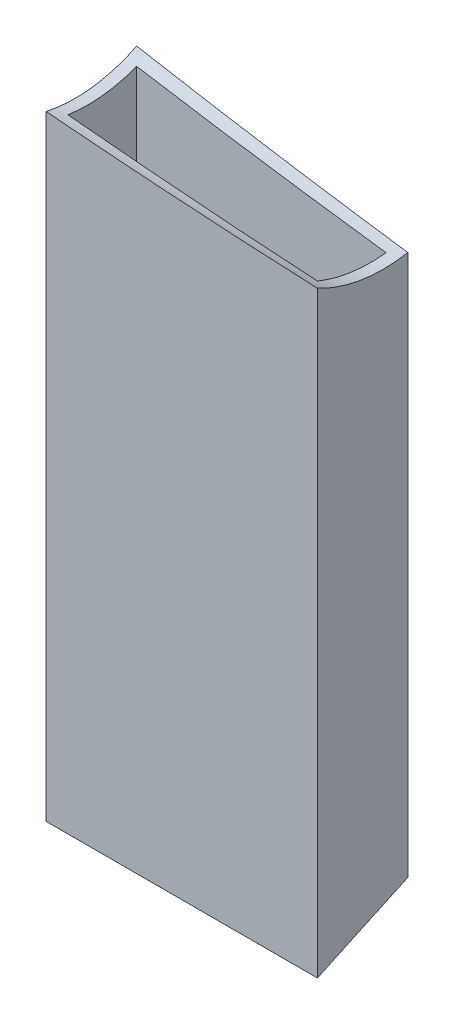
from build123d import *

# Parameters (mm, degrees)
SKETCH1_W           = 76.2
SKETCH1_H           = 25.4
SKETCH1_W_2         = 70.104
SKETCH1_H_2         = 19.304
BOSS_EXTRUDE1_DEPTH = 200
SKETCH3_W           = 76.2
SKETCH3_H           = 25.4
SKETCH3_W_2         = 70.104
SKETCH3_H_2         = 19.304
BOSS_EXTRUDE2_DEPTH = 38.1
CUT_EXTRUDE1_DEPTH  = 77.2
CUT_EXTRUDE5_START  = 13.832764
SKETCH7_R           = 38.1
CUT_EXTRUDE5_DEPTH  = 83.124802


with BuildPart() as part:
    # Sketch1 → Boss-Extrude1 (new body)
    with BuildSketch(Plane(origin=(0, 0, 0), x_dir=(1, 0, 0), z_dir=(0, 1, 0))):
        Rectangle(SKETCH1_W, SKETCH1_H)
        Rectangle(SKETCH1_W_2, SKETCH1_H_2, mode=Mode.SUBTRACT)
    extrude(amount=BOSS_EXTRUDE1_DEPTH)

    # Sketch3 → Boss-Extrude2 (add)
    with BuildSketch(Plane.XZ):
        Rectangle(SKETCH3_W, SKETCH3_H)
        Rectangle(SKETCH3_W_2, SKETCH3_H_2, mode=Mode.SUBTRACT)
    extrude(amount=BOSS_EXTRUDE2_DEPTH)

    # Sketch4 → Cut-Extrude1 (cut, through all)
    with BuildSketch(Plane(origin=(38.1, 0, 0), x_dir=(0, 0, -1), z_dir=(1, 0, 0))):
        Polygon((-18.94463971, -8.788530579), (21.02313948, 9.752758934), (26.07322677, -49.294265894), (-15.918593218, -47.517542491), align=None)
    extrude(amount=-CUT_EXTRUDE1_DEPTH, mode=Mode.SUBTRACT)

    # Sketch7 → Cut-Extrude5 (cut)
    with BuildSketch(Plane(origin=(56.875227758, 193.523427606, -7.656864493), x_dir=(0.131571603, -0.016382038, 0.991171298), z_dir=(-0.984807753, 0.112143352, 0.132580384)).offset(CUT_EXTRUDE5_START)):
        Circle(SKETCH7_R)
    extrude(amount=CUT_EXTRUDE5_DEPTH, mode=Mode.SUBTRACT)


solid = part.part
